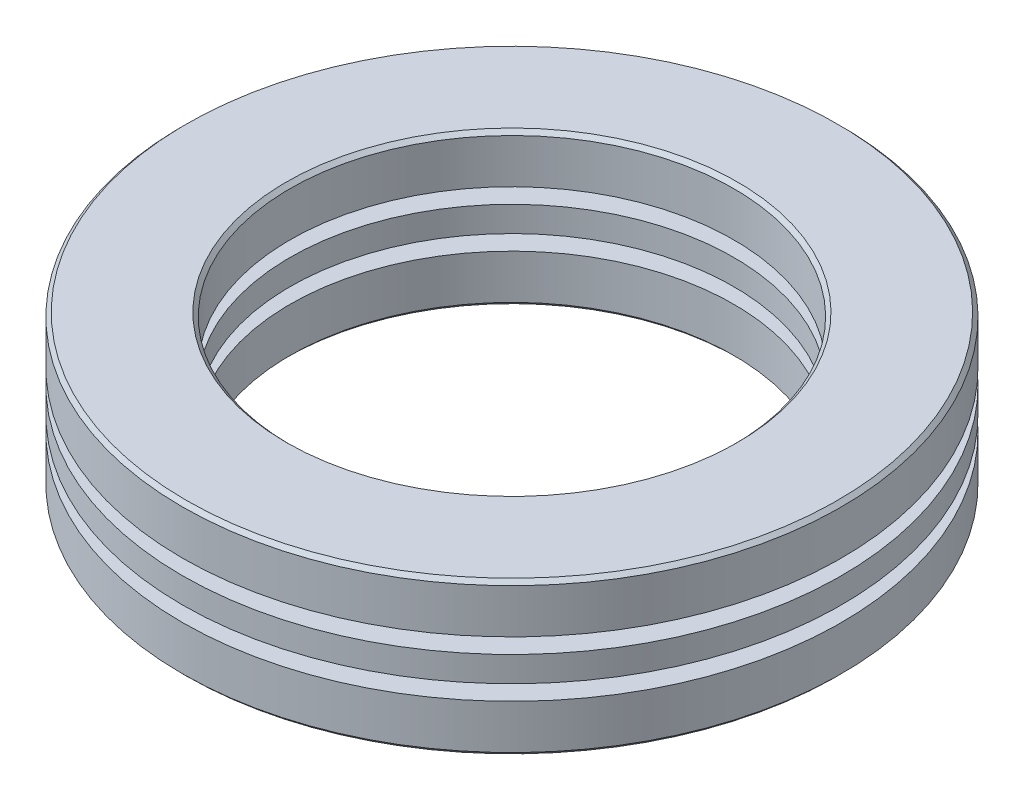
from build123d import *

# Parameters (mm, degrees)
SKETCH1_R           = 26
SKETCH1_R_2         = 17.5
BOSS_EXTRUDE1_DEPTH = 3.8
SKETCH2_R           = 26
SKETCH2_R_2         = 17.5
BOSS_EXTRUDE2_DEPTH = 2
SKETCH3_R           = 26
SKETCH3_R_2         = 17.5
BOSS_EXTRUDE3_DEPTH = 3.8
CIRPATTERN2_COUNT   = 16
CIRPATTERN3_COUNT   = 16
CHAMFER1_SIZE       = 0.3
CHAMFER2_SIZE       = 0.3


with BuildPart() as part:
    # Sketch1 → Boss-Extrude1 (new body)
    with BuildSketch(Plane(origin=(0, 0, 0), x_dir=(1, 0, 0), z_dir=(0, 1, 0))):
        Circle(SKETCH1_R)
        Circle(SKETCH1_R_2, mode=Mode.SUBTRACT)
    extrude(amount=BOSS_EXTRUDE1_DEPTH)

    # Chamfer1
    chamfer1_edges = [part.edges().sort_by_distance(p)[0] for p in [
        (-26, 0, 0),
        (-17.5, 0, 0),
    ]]
    chamfer(chamfer1_edges, length=CHAMFER1_SIZE)


with BuildPart() as body_2:
    # Sketch2 → Boss-Extrude2 (new body)
    with BuildSketch(Plane(origin=(0, 5, 0), x_dir=(1, 0, 0), z_dir=(0, 1, 0))):
        Circle(SKETCH2_R)
        Circle(SKETCH2_R_2, mode=Mode.SUBTRACT)
    extrude(amount=BOSS_EXTRUDE2_DEPTH)

    # Sketch4 → Cut-Revolve1 (revolve, cut)
    with BuildSketch(Plane.XY):
        with BuildLine():
            Line((-23.95, 6), (-19.55, 6))
            ThreePointArc((-19.55, 6), (-21.75, 8.2), (-23.95, 6))
        make_face()
    cut_revolve1 = revolve(axis=Axis((-23.95, 6, 0), (1, 0, 0)), mode=Mode.SUBTRACT)

    # CirPattern2: Cut-Revolve1 ×16 about axis
    cirpattern2_axis = Axis((0, 0, 0), (0, -1, 0))
    for i in range(1, CIRPATTERN2_COUNT):
        add(cut_revolve1.rotate(cirpattern2_axis, i * 360 / CIRPATTERN2_COUNT), mode=Mode.SUBTRACT)


with BuildPart() as body_3:
    # Sketch3 → Boss-Extrude3 (new body)
    with BuildSketch(Plane(origin=(0, 8.2, 0), x_dir=(1, 0, 0), z_dir=(0, 1, 0))):
        Circle(SKETCH3_R)
        Circle(SKETCH3_R_2, mode=Mode.SUBTRACT)
    extrude(amount=BOSS_EXTRUDE3_DEPTH)

    # Chamfer2
    chamfer2_edges = [body_3.edges().sort_by_distance(p)[0] for p in [
        (-26, 12, 0),
        (-17.5, 12, 0),
    ]]
    chamfer(chamfer2_edges, length=CHAMFER2_SIZE)


with BuildPart() as body_4:
    # Sketch4_2 → Revolve1 (revolve)
    with BuildSketch(Plane.XY):
        with BuildLine():
            Line((-23.95, 6), (-19.55, 6))
            ThreePointArc((-19.55, 6), (-21.75, 8.2), (-23.95, 6))
        make_face()
    revolve(axis=Axis((-23.95, 6, 0), (1, 0, 0)))


with BuildPart() as cirpattern3_1:
    # CirPattern3: pattern copy
    add(body_4.part.rotate(Axis((0, 0, 0), (0, -1, 0)), 1 * 360 / CIRPATTERN3_COUNT))


with BuildPart() as cirpattern3_2:
    # CirPattern3: pattern copy
    add(body_4.part.rotate(Axis((0, 0, 0), (0, -1, 0)), 2 * 360 / CIRPATTERN3_COUNT))


with BuildPart() as cirpattern3_3:
    # CirPattern3: pattern copy
    add(body_4.part.rotate(Axis((0, 0, 0), (0, -1, 0)), 3 * 360 / CIRPATTERN3_COUNT))


with BuildPart() as cirpattern3_4:
    # CirPattern3: pattern copy
    add(body_4.part.rotate(Axis((0, 0, 0), (0, -1, 0)), 4 * 360 / CIRPATTERN3_COUNT))


with BuildPart() as cirpattern3_5:
    # CirPattern3: pattern copy
    add(body_4.part.rotate(Axis((0, 0, 0), (0, -1, 0)), 5 * 360 / CIRPATTERN3_COUNT))


with BuildPart() as cirpattern3_6:
    # CirPattern3: pattern copy
    add(body_4.part.rotate(Axis((0, 0, 0), (0, -1, 0)), 6 * 360 / CIRPATTERN3_COUNT))


with BuildPart() as cirpattern3_7:
    # CirPattern3: pattern copy
    add(body_4.part.rotate(Axis((0, 0, 0), (0, -1, 0)), 7 * 360 / CIRPATTERN3_COUNT))


with BuildPart() as cirpattern3_8:
    # CirPattern3: pattern copy
    add(body_4.part.rotate(Axis((0, 0, 0), (0, -1, 0)), 8 * 360 / CIRPATTERN3_COUNT))


with BuildPart() as cirpattern3_9:
    # CirPattern3: pattern copy
    add(body_4.part.rotate(Axis((0, 0, 0), (0, -1, 0)), 9 * 360 / CIRPATTERN3_COUNT))


with BuildPart() as cirpattern3_10:
    # CirPattern3: pattern copy
    add(body_4.part.rotate(Axis((0, 0, 0), (0, -1, 0)), 10 * 360 / CIRPATTERN3_COUNT))


with BuildPart() as cirpattern3_11:
    # CirPattern3: pattern copy
    add(body_4.part.rotate(Axis((0, 0, 0), (0, -1, 0)), 11 * 360 / CIRPATTERN3_COUNT))


with BuildPart() as cirpattern3_12:
    # CirPattern3: pattern copy
    add(body_4.part.rotate(Axis((0, 0, 0), (0, -1, 0)), 12 * 360 / CIRPATTERN3_COUNT))


with BuildPart() as cirpattern3_13:
    # CirPattern3: pattern copy
    add(body_4.part.rotate(Axis((0, 0, 0), (0, -1, 0)), 13 * 360 / CIRPATTERN3_COUNT))


with BuildPart() as cirpattern3_14:
    # CirPattern3: pattern copy
    add(body_4.part.rotate(Axis((0, 0, 0), (0, -1, 0)), 14 * 360 / CIRPATTERN3_COUNT))


with BuildPart() as cirpattern3_15:
    # CirPattern3: pattern copy
    add(body_4.part.rotate(Axis((0, 0, 0), (0, -1, 0)), 15 * 360 / CIRPATTERN3_COUNT))


solid = Compound([part.part, body_2.part, body_3.part, body_4.part, cirpattern3_1.part, cirpattern3_2.part, cirpattern3_3.part, cirpattern3_4.part, cirpattern3_5.part, cirpattern3_6.part, cirpattern3_7.part, cirpattern3_8.part, cirpattern3_9.part, cirpattern3_10.part, cirpattern3_11.part, cirpattern3_12.part, cirpattern3_13.part, cirpattern3_14.part, cirpattern3_15.part])
